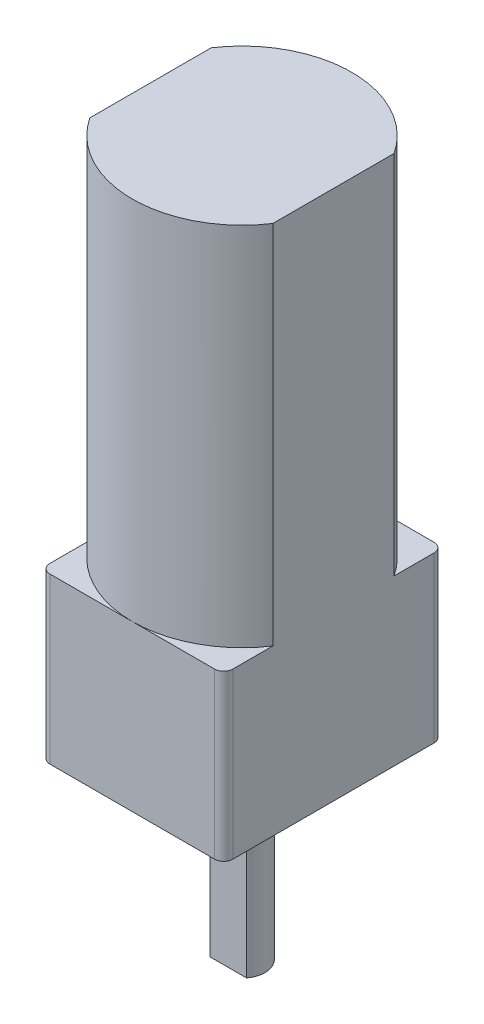
from build123d import *

# Parameters (mm, degrees)
SKETCH2_W           = 10
SKETCH2_H           = 12
BOSS_EXTRUDE1_DEPTH = 15
FILLET2_R           = 2.5
FILLET3_R           = 2.5
FILLET4_R           = 2.5
FILLET5_R           = 2.5
BOSS_EXTRUDE2_DEPTH = 9
FILLET6_R           = 0.5
SKETCH4_R           = 2
SKETCH4_R_2         = 1.25
BOSS_EXTRUDE4_DEPTH = 0.8
SKETCH5_R           = 1.25
BOSS_EXTRUDE5_DEPTH = 10
CUT_EXTRUDE1_DEPTH  = 9.2
CUT_EXTRUDE2_DEPTH  = 15
BOSS_EXTRUDE7_DEPTH = 20


with BuildPart() as part:
    # Sketch2 → Boss-Extrude1 (new body)
    with BuildSketch(Plane(origin=(0, 0, 0), x_dir=(1, 0, 0), z_dir=(0, 1, 0))):
        with Locations((-5, -6)):
            Rectangle(SKETCH2_W, SKETCH2_H)
    extrude(amount=BOSS_EXTRUDE1_DEPTH)

    # Fillet2
    fillet2_edges = [part.edges().sort_by_distance(p)[0] for p in [
        (0, 7.5, 0),
    ]]
    fillet(fillet2_edges, radius=FILLET2_R)

    # Fillet3
    fillet3_edges = [part.edges().sort_by_distance(p)[0] for p in [
        (-10, 7.5, 0),
    ]]
    fillet(fillet3_edges, radius=FILLET3_R)

    # Fillet4
    fillet4_edges = [part.edges().sort_by_distance(p)[0] for p in [
        (-10, 7.5, 12),
    ]]
    fillet(fillet4_edges, radius=FILLET4_R)

    # Fillet5
    fillet5_edges = [part.edges().sort_by_distance(p)[0] for p in [
        (0, 7.5, 12),
    ]]
    fillet(fillet5_edges, radius=FILLET5_R)

    # Sketch3 → Boss-Extrude2 (add)
    with BuildSketch(Plane.XZ):
        with BuildLine():
            Line((0, 0), (0, 2.5))
            ThreePointArc((0, 2.5), (-0.732233047, 0.732233047), (-2.5, 0))
            Line((-2.5, 0), (0, 0))
        make_face()
        with BuildLine():
            ThreePointArc((-2.5, 0), (-0.732233047, 0.732233047), (0, 2.5))
            Line((0, 2.5), (-5, 6))
            Line((-5, 6), (-10, 2.5))
            ThreePointArc((-10, 2.5), (-9.267766953, 0.732233047), (-7.5, 0))
            Line((-7.5, 0), (-2.5, 0))
        make_face()
        with BuildLine():
            ThreePointArc((-7.5, 0), (-9.267766953, 0.732233047), (-10, 2.5))
            Line((-10, 2.5), (-10, 0))
            Line((-10, 0), (-7.5, 0))
        make_face()
        Polygon((-5, 6), (0, 2.5), (0, 9.5), align=None)
        Polygon((-10, 2.5), (-5, 6), (-10, 9.5), align=None)
        with BuildLine():
            Line((-10, 9.5), (-5, 6))
            Line((-5, 6), (0, 9.5))
            ThreePointArc((0, 9.5), (-0.732233047, 11.267766953), (-2.5, 12))
            Line((-2.5, 12), (-7.5, 12))
            ThreePointArc((-7.5, 12), (-9.267766953, 11.267766953), (-10, 9.5))
        make_face()
        with BuildLine():
            Line((-10, 12), (-10, 9.5))
            ThreePointArc((-10, 9.5), (-9.267766953, 11.267766953), (-7.5, 12))
            Line((-7.5, 12), (-10, 12))
        make_face()
        with BuildLine():
            ThreePointArc((-2.5, 12), (-0.732233047, 11.267766953), (0, 9.5))
            Line((0, 9.5), (0, 12))
            Line((0, 12), (-2.5, 12))
        make_face()
    extrude(amount=BOSS_EXTRUDE2_DEPTH)

    # Fillet6
    fillet6_edges = [part.edges().sort_by_distance(p)[0] for p in [
        (0, -4.5, 12),
        (-10, -4.5, 12),
        (-10, -4.5, 0),
        (0, -4.5, 0),
    ]]
    fillet(fillet6_edges, radius=FILLET6_R)

    # Sketch4 → Boss-Extrude4 (add)
    with BuildSketch(Plane.XZ.offset(9)):
        with Locations((-5, 6)):
            Circle(SKETCH4_R)
        with Locations((-5, 6)):
            Circle(SKETCH4_R_2, mode=Mode.SUBTRACT)
    extrude(amount=BOSS_EXTRUDE4_DEPTH)

    # Sketch5 → Boss-Extrude5 (add)
    with BuildSketch(Plane.XZ.offset(9)):
        with Locations((-5, 6)):
            Circle(SKETCH5_R)
    extrude(amount=BOSS_EXTRUDE5_DEPTH)

    # Sketch6 → Cut-Extrude1 (cut)
    with BuildSketch(Plane.XZ.offset(19)):
        with BuildLine():
            Line((-6, 6.75), (-5, 6.75))
            Line((-5, 6.75), (-4, 6.75))
            ThreePointArc((-4, 6.75), (-5, 7.25), (-6, 6.75))
        make_face()
    extrude(amount=-CUT_EXTRUDE1_DEPTH, mode=Mode.SUBTRACT)

    # Sketch8 → Cut-Extrude2 (cut)
    with BuildSketch(Plane(origin=(0, 15, 0), x_dir=(1, 0, 0), z_dir=(0, 1, 0))):
        with BuildLine():
            Line((-7.5, -12), (-2.5, -12))
            ThreePointArc((-2.5, -12), (-0.732233047, -11.267766953), (0, -9.5))
            Line((0, -9.5), (0, -2.5))
            ThreePointArc((0, -2.5), (-0.732233047, -0.732233047), (-2.5, 0))
            Line((-2.5, 0), (-7.5, 0))
            ThreePointArc((-7.5, 0), (-9.267766953, -0.732233047), (-10, -2.5))
            Line((-10, -2.5), (-10, -9.5))
            ThreePointArc((-10, -9.5), (-9.267766953, -11.267766953), (-7.5, -12))
        make_face()
    extrude(amount=-CUT_EXTRUDE2_DEPTH, mode=Mode.SUBTRACT)

    # Sketch9 → Boss-Extrude7 (add)
    with BuildSketch(Plane(origin=(0, 0, 0), x_dir=(1, 0, 0), z_dir=(0, 1, 0))):
        with BuildLine():
            Line((0, -9.31662479), (0, -2.68337521))
            ThreePointArc((0, -2.68337521), (-5, 0), (-10, -2.68337521))
            Line((-10, -2.68337521), (-10, -9.31662479))
            ThreePointArc((-10, -9.31662479), (-5, -12), (0, -9.31662479))
        make_face()
    extrude(amount=BOSS_EXTRUDE7_DEPTH)


solid = part.part
